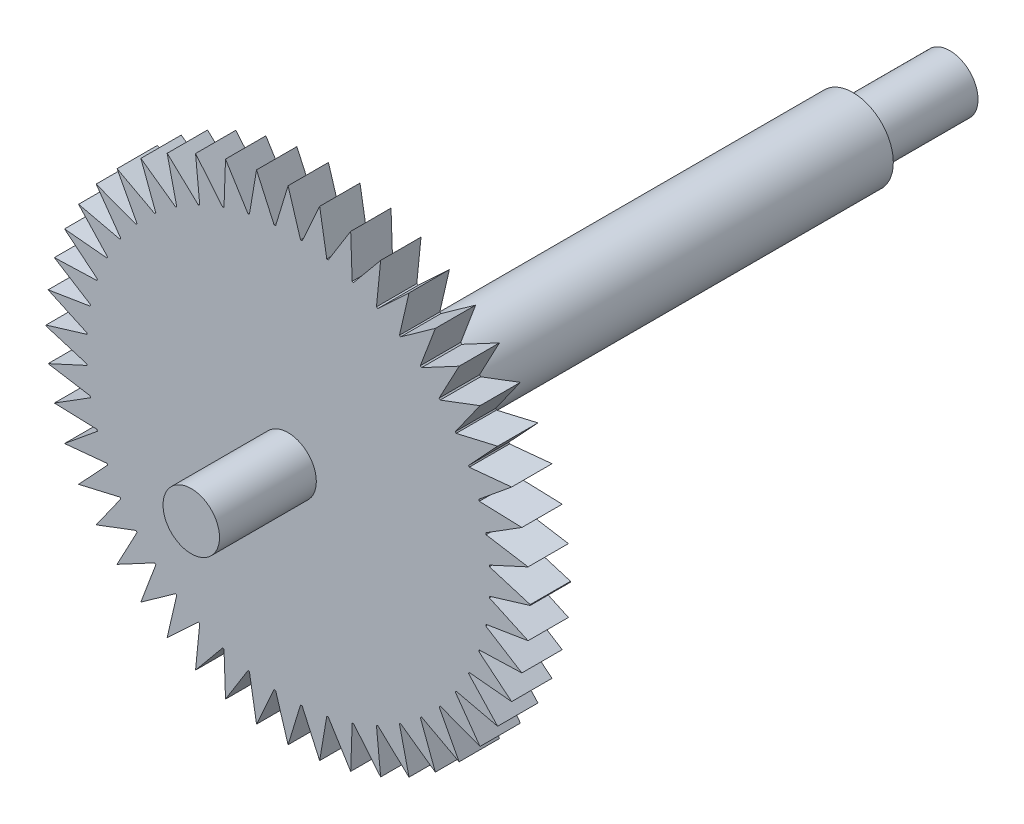
from build123d import *

# Parameters (mm, degrees)
ESQUISSE1_R             = 5
BOSS_EXTRU_1_DEPTH      = 70
ESQUISSE2_R             = 30
BOSS_EXTRU_2_DEPTH      = 5
ESQUISSE3_R             = 3.5
BOSS_EXTRU_3_DEPTH      = 12
ESQUISSE4_R             = 3.5
BOSS_EXTRU_4_DEPTH      = 12
ENL_V_MAT_EXTRU_1_DEPTH = 10


with BuildPart() as part:
    # Esquisse1 → Boss.-Extru.1 (new body)
    with BuildSketch(Plane.XY):
        Circle(ESQUISSE1_R)
    extrude(amount=BOSS_EXTRU_1_DEPTH)

    # Esquisse2 → Boss.-Extru.2 (add)
    with BuildSketch(Plane.XY.offset(70)):
        Circle(ESQUISSE2_R)
    extrude(amount=-BOSS_EXTRU_2_DEPTH)

    # Esquisse3 → Boss.-Extru.3 (add)
    with BuildSketch(Plane(origin=(0, 0, 0), x_dir=(-1, 0, 0), z_dir=(0, 0, -1))):
        Circle(ESQUISSE3_R)
    extrude(amount=BOSS_EXTRU_3_DEPTH)

    # Esquisse4 → Boss.-Extru.4 (add)
    with BuildSketch(Plane.XY.offset(70)):
        Circle(ESQUISSE4_R)
    extrude(amount=BOSS_EXTRU_4_DEPTH)

    # Esquisse5 → Enlèv. mat.-Extru.1 (cut)
    with BuildSketch(Plane.XY.offset(70)):
        with BuildLine():
            ThreePointArc((3.911624902, 29.743893333), (1.96, 29.935904864), (0, 30))
            Line((0, 30), (1.54, 24.952522919))
            ThreePointArc((1.54, 24.952522919), (1.639797772, 24.946163298), (1.739569306, 24.939404536))
            Line((1.739569306, 24.939404536), (3.911624902, 29.743893333))
        make_face()
        with BuildLine():
            Line((-1.54, 24.952522919), (0, 30))
            ThreePointArc((0, 30), (-1.96, 29.935904864), (-3.911624902, 29.743893333))
            Line((-3.911624902, 29.743893333), (-1.739569306, 24.939404536))
            ThreePointArc((-1.739569306, 24.939404536), (-1.639797772, 24.946163298), (-1.54, 24.952522919))
        make_face()
        with BuildLine():
            ThreePointArc((7.75646359, 28.979946042), (5.846535396, 29.424785876), (3.911624902, 29.743893333))
            Line((3.911624902, 29.743893333), (4.793067146, 24.536228466))
            ThreePointArc((4.793067146, 24.536228466), (4.878466786, 24.519391547), (4.963807286, 24.50225739))
            Line((4.963807286, 24.50225739), (7.75646359, 28.979946042))
        make_face()
        with BuildLine():
            Line((-4.793067146, 24.536228466), (-3.911624902, 29.743893333))
            ThreePointArc((-3.911624902, 29.743893333), (-5.846535396, 29.424785876), (-7.75646359, 28.979946042))
            Line((-7.75646359, 28.979946042), (-4.963807286, 24.50225739))
            ThreePointArc((-4.963807286, 24.50225739), (-4.878466786, 24.519391547), (-4.793067146, 24.536228466))
        make_face()
        with BuildLine():
            ThreePointArc((11.468870142, 27.721201591), (9.633248345, 28.411274634), (7.75646359, 28.979946042))
            Line((7.75646359, 28.979946042), (7.939081747, 23.705927128))
            ThreePointArc((7.939081747, 23.705927128), (8.021571427, 23.678141647), (8.103963866, 23.650069126))
            Line((8.103963866, 23.650069126), (11.468870142, 27.721201591))
        make_face()
        with BuildLine():
            Line((-7.939081747, 23.705927128), (-7.75646359, 28.979946042))
            ThreePointArc((-7.75646359, 28.979946042), (-9.633248345, 28.411274634), (-11.468870142, 27.721201591))
            Line((-11.468870142, 27.721201591), (-8.103963866, 23.650069126))
            ThreePointArc((-8.103963866, 23.650069126), (-8.021571427, 23.678141647), (-7.939081747, 23.705927128))
        make_face()
        with BuildLine():
            ThreePointArc((14.985459754, 25.989151505), (13.255485353, 26.912675602), (11.468870142, 27.721201591))
            Line((11.468870142, 27.721201591), (10.950617091, 22.474073626))
            ThreePointArc((10.950617091, 22.474073626), (11.04042578, 22.430091364), (11.130057821, 22.38575022))
            Line((11.130057821, 22.38575022), (14.985459754, 25.989151505))
        make_face()
        with BuildLine():
            Line((-10.950617091, 22.474073626), (-11.468870142, 27.721201591))
            ThreePointArc((-11.468870142, 27.721201591), (-13.255485353, 26.912675602), (-14.985459754, 25.989151505))
            Line((-14.985459754, 25.989151505), (-11.130057821, 22.38575022))
            ThreePointArc((-11.130057821, 22.38575022), (-11.04042578, 22.430091364), (-10.950617091, 22.474073626))
        make_face()
        with BuildLine():
            ThreePointArc((18.246190956, 23.813368422), (16.65140115, 24.954575527), (14.985459754, 25.989151505))
            Line((14.985459754, 25.989151505), (13.798277376, 20.847243018))
            ThreePointArc((13.798277376, 20.847243018), (13.870778356, 20.799074686), (13.943111187, 20.750654217))
            Line((13.943111187, 20.750654217), (18.246190956, 23.813368422))
        make_face()
        with BuildLine():
            Line((-13.798277376, 20.847243018), (-14.985459754, 25.989151505))
            ThreePointArc((-14.985459754, 25.989151505), (-16.65140115, 24.954575527), (-18.246190956, 23.813368422))
            Line((-18.246190956, 23.813368422), (-13.943111187, 20.750654217))
            ThreePointArc((-13.943111187, 20.750654217), (-13.870778356, 20.799074686), (-13.798277376, 20.847243018))
        make_face()
        with BuildLine():
            ThreePointArc((21.195390749, 21.231001177), (19.763014623, 22.570406576), (18.246190956, 23.813368422))
            Line((18.246190956, 23.813368422), (16.388920873, 18.878645942))
            ThreePointArc((16.388920873, 18.878645942), (16.464304345, 18.812939229), (16.539424387, 18.746931507))
            Line((16.539424387, 18.746931507), (21.195390749, 21.231001177))
        make_face()
        with BuildLine():
            Line((-16.388920873, 18.878645942), (-18.246190956, 23.813368422))
            ThreePointArc((-18.246190956, 23.813368422), (-19.763014623, 22.570406576), (-21.195390749, 21.231001177))
            Line((-21.195390749, 21.231001177), (-16.539424387, 18.746931507))
            ThreePointArc((-16.539424387, 18.746931507), (-16.464304345, 18.812939229), (-16.388920873, 18.878645942))
        make_face()
        with BuildLine():
            ThreePointArc((23.78270515, 18.286140537), (22.537198777, 19.800875518), (21.195390749, 21.231001177))
            Line((21.195390749, 21.231001177), (18.719140508, 16.57087139))
            ThreePointArc((18.719140508, 16.57087139), (18.78527424, 16.495862261), (18.851107406, 16.420589196))
            Line((18.851107406, 16.420589196), (23.78270515, 18.286140537))
        make_face()
        with BuildLine():
            Line((-18.719140508, 16.57087139), (-21.195390749, 21.231001177))
            ThreePointArc((-21.195390749, 21.231001177), (-22.537198777, 19.800875518), (-23.78270515, 18.286140537))
            Line((-23.78270515, 18.286140537), (-18.851107406, 16.420589196))
            ThreePointArc((-18.851107406, 16.420589196), (-18.78527424, 16.495862261), (-18.719140508, 16.57087139))
        make_face()
        with BuildLine():
            ThreePointArc((25.963958928, 15.029066397), (24.926587807, 16.693268712), (23.78270515, 18.286140537))
            Line((23.78270515, 18.286140537), (20.727218802, 13.97792548))
            ThreePointArc((20.727218802, 13.97792548), (20.775760628, 13.905674034), (20.824050599, 13.833254016))
            Line((20.824050599, 13.833254016), (25.963958928, 15.029066397))
        make_face()
        with BuildLine():
            Line((-20.727218802, 13.97792548), (-23.78270515, 18.286140537))
            ThreePointArc((-23.78270515, 18.286140537), (-24.926587807, 16.693268712), (-25.963958928, 15.029066397))
            Line((-25.963958928, 15.029066397), (-20.824050599, 13.833254016))
            ThreePointArc((-20.824050599, 13.833254016), (-20.775760628, 13.905674034), (-20.727218802, 13.97792548))
        make_face()
        with BuildLine():
            ThreePointArc((27.701909842, 11.515389317), (26.890385817, 13.300644745), (25.963958928, 15.029066397))
            Line((25.963958928, 15.029066397), (22.367034749, 11.167620899))
            ThreePointArc((22.367034749, 11.167620899), (22.405781894, 11.089677079), (22.444257425, 11.011598824))
            Line((22.444257425, 11.011598824), (27.701909842, 11.515389317))
        make_face()
        with BuildLine():
            Line((-22.367034749, 11.167620899), (-25.963958928, 15.029066397))
            ThreePointArc((-25.963958928, 15.029066397), (-26.890385817, 13.300644745), (-27.701909842, 11.515389317))
            Line((-27.701909842, 11.515389317), (-22.444257425, 11.011598824))
            ThreePointArc((-22.444257425, 11.011598824), (-22.405781894, 11.089677079), (-22.367034749, 11.167620899))
        make_face()
        with BuildLine():
            ThreePointArc((28.966884502, 7.805101039), (28.395063354, 9.680928526), (27.701909842, 11.515389317))
            Line((27.701909842, 11.515389317), (23.627977885, 8.168149181))
            ThreePointArc((23.627977885, 8.168149181), (23.660461458, 8.073571924), (23.692566461, 7.97886549))
            Line((23.692566461, 7.97886549), (28.966884502, 7.805101039))
        make_face()
        with BuildLine():
            Line((-23.627977885, 8.168149181), (-27.701909842, 11.515389317))
            ThreePointArc((-27.701909842, 11.515389317), (-28.395063354, 9.680928526), (-28.966884502, 7.805101039))
            Line((-28.966884502, 7.805101039), (-23.692566461, 7.97886549))
            ThreePointArc((-23.692566461, 7.97886549), (-23.660461458, 8.073571924), (-23.627977885, 8.168149181))
        make_face()
        with BuildLine():
            ThreePointArc((29.737285014, 3.9615502), (29.41492989, 5.895922284), (28.966884502, 7.805101039))
            Line((28.966884502, 7.805101039), (24.493890167, 5.004932014))
            ThreePointArc((24.493890167, 5.004932014), (24.513713944, 4.906916414), (24.533145499, 4.808822302))
            Line((24.533145499, 4.808822302), (29.737285014, 3.9615502))
        make_face()
        with BuildLine():
            Line((-24.493890167, 5.004932014), (-28.966884502, 7.805101039))
            ThreePointArc((-28.966884502, 7.805101039), (-29.41492989, 5.895922284), (-29.737285014, 3.9615502))
            Line((-29.737285014, 3.9615502), (-24.533145499, 4.808822302))
            ThreePointArc((-24.533145499, 4.808822302), (-24.513713944, 4.906916414), (-24.493890167, 5.004932014))
        make_face()
        with BuildLine():
            ThreePointArc((29.99995773, 0.050360733), (29.932572449, 2.010250376), (29.737285014, 3.9615502))
            Line((29.737285014, 3.9615502), (24.938282315, 1.755583995))
            ThreePointArc((24.938282315, 1.755583995), (24.944243639, 1.668744817), (24.949902576, 1.581885408))
            Line((24.949902576, 1.581885408), (29.99995773, 0.050360733))
        make_face()
        with BuildLine():
            Line((-24.938282315, 1.755583995), (-29.737285014, 3.9615502))
            ThreePointArc((-29.737285014, 3.9615502), (-29.932572449, 2.010250376), (-29.99995773, 0.050360733))
            Line((-29.99995773, 0.050360733), (-24.949902576, 1.581885408))
            ThreePointArc((-24.949902576, 1.581885408), (-24.944243639, 1.668744817), (-24.938282315, 1.755583995))
        make_face()
        with BuildLine():
            Line((-24.949902576, -1.581885408), (-29.99995773, -0.050360733))
            ThreePointArc((-29.99995773, -0.050360733), (-29.932572449, -2.010250376), (-29.737285014, -3.9615502))
            Line((-29.737285014, -3.9615502), (-24.938282315, -1.755583995))
            ThreePointArc((-24.938282315, -1.755583995), (-24.944243639, -1.668744817), (-24.949902576, -1.581885408))
        make_face()
        with BuildLine():
            ThreePointArc((29.737285014, -3.9615502), (29.932572449, -2.010250376), (29.99995773, -0.050360733))
            Line((29.99995773, -0.050360733), (24.949902576, -1.581885408))
            ThreePointArc((24.949902576, -1.581885408), (24.944243639, -1.668744817), (24.938282315, -1.755583995))
            Line((24.938282315, -1.755583995), (29.737285014, -3.9615502))
        make_face()
        with BuildLine():
            Line((-24.533145499, -4.808822302), (-29.737285014, -3.9615502))
            ThreePointArc((-29.737285014, -3.9615502), (-29.41492989, -5.895922284), (-28.966884502, -7.805101039))
            Line((-28.966884502, -7.805101039), (-24.493890167, -5.004932014))
            ThreePointArc((-24.493890167, -5.004932014), (-24.513713944, -4.906916414), (-24.533145499, -4.808822302))
        make_face()
        with BuildLine():
            ThreePointArc((28.966884502, -7.805101039), (29.41492989, -5.895922284), (29.737285014, -3.9615502))
            Line((29.737285014, -3.9615502), (24.533145499, -4.808822302))
            ThreePointArc((24.533145499, -4.808822302), (24.513713944, -4.906916414), (24.493890167, -5.004932014))
            Line((24.493890167, -5.004932014), (28.966884502, -7.805101039))
        make_face()
        with BuildLine():
            Line((-23.692566461, -7.97886549), (-28.966884502, -7.805101039))
            ThreePointArc((-28.966884502, -7.805101039), (-28.395063354, -9.680928526), (-27.701909842, -11.515389317))
            Line((-27.701909842, -11.515389317), (-23.627977885, -8.168149181))
            ThreePointArc((-23.627977885, -8.168149181), (-23.660461458, -8.073571924), (-23.692566461, -7.97886549))
        make_face()
        with BuildLine():
            ThreePointArc((27.701909842, -11.515389317), (28.395063354, -9.680928526), (28.966884502, -7.805101039))
            Line((28.966884502, -7.805101039), (23.692566461, -7.97886549))
            ThreePointArc((23.692566461, -7.97886549), (23.660461458, -8.073571924), (23.627977885, -8.168149181))
            Line((23.627977885, -8.168149181), (27.701909842, -11.515389317))
        make_face()
        with BuildLine():
            Line((-22.444257425, -11.011598824), (-27.701909842, -11.515389317))
            ThreePointArc((-27.701909842, -11.515389317), (-26.890385817, -13.300644745), (-25.963958928, -15.029066397))
            Line((-25.963958928, -15.029066397), (-22.367034749, -11.167620899))
            ThreePointArc((-22.367034749, -11.167620899), (-22.405781894, -11.089677079), (-22.444257425, -11.011598824))
        make_face()
        with BuildLine():
            ThreePointArc((25.963958928, -15.029066397), (26.890385817, -13.300644745), (27.701909842, -11.515389317))
            Line((27.701909842, -11.515389317), (22.444257425, -11.011598824))
            ThreePointArc((22.444257425, -11.011598824), (22.405781894, -11.089677079), (22.367034749, -11.167620899))
            Line((22.367034749, -11.167620899), (25.963958928, -15.029066397))
        make_face()
        with BuildLine():
            Line((-20.824050599, -13.833254016), (-25.963958928, -15.029066397))
            ThreePointArc((-25.963958928, -15.029066397), (-24.926587807, -16.693268712), (-23.78270515, -18.286140537))
            Line((-23.78270515, -18.286140537), (-20.727218802, -13.97792548))
            ThreePointArc((-20.727218802, -13.97792548), (-20.775760628, -13.905674034), (-20.824050599, -13.833254016))
        make_face()
        with BuildLine():
            ThreePointArc((23.78270515, -18.286140537), (24.926587807, -16.693268712), (25.963958928, -15.029066397))
            Line((25.963958928, -15.029066397), (20.824050599, -13.833254016))
            ThreePointArc((20.824050599, -13.833254016), (20.775760628, -13.905674034), (20.727218802, -13.97792548))
            Line((20.727218802, -13.97792548), (23.78270515, -18.286140537))
        make_face()
        with BuildLine():
            Line((-18.851107406, -16.420589196), (-23.78270515, -18.286140537))
            ThreePointArc((-23.78270515, -18.286140537), (-22.537198777, -19.800875518), (-21.195390749, -21.231001177))
            Line((-21.195390749, -21.231001177), (-18.719140508, -16.57087139))
            ThreePointArc((-18.719140508, -16.57087139), (-18.78527424, -16.495862261), (-18.851107406, -16.420589196))
        make_face()
        with BuildLine():
            ThreePointArc((21.195390749, -21.231001177), (22.537198777, -19.800875518), (23.78270515, -18.286140537))
            Line((23.78270515, -18.286140537), (18.851107406, -16.420589196))
            ThreePointArc((18.851107406, -16.420589196), (18.78527424, -16.495862261), (18.719140508, -16.57087139))
            Line((18.719140508, -16.57087139), (21.195390749, -21.231001177))
        make_face()
        with BuildLine():
            Line((-16.539424387, -18.746931507), (-21.195390749, -21.231001177))
            ThreePointArc((-21.195390749, -21.231001177), (-19.763014623, -22.570406576), (-18.246190956, -23.813368422))
            Line((-18.246190956, -23.813368422), (-16.388920873, -18.878645942))
            ThreePointArc((-16.388920873, -18.878645942), (-16.464304345, -18.812939229), (-16.539424387, -18.746931507))
        make_face()
        with BuildLine():
            ThreePointArc((18.246190956, -23.813368422), (19.763014623, -22.570406576), (21.195390749, -21.231001177))
            Line((21.195390749, -21.231001177), (16.539424387, -18.746931507))
            ThreePointArc((16.539424387, -18.746931507), (16.464304345, -18.812939229), (16.388920873, -18.878645942))
            Line((16.388920873, -18.878645942), (18.246190956, -23.813368422))
        make_face()
        with BuildLine():
            Line((-13.943111187, -20.750654217), (-18.246190956, -23.813368422))
            ThreePointArc((-18.246190956, -23.813368422), (-16.65140115, -24.954575527), (-14.985459754, -25.989151505))
            Line((-14.985459754, -25.989151505), (-13.798277376, -20.847243018))
            ThreePointArc((-13.798277376, -20.847243018), (-13.870778356, -20.799074686), (-13.943111187, -20.750654217))
        make_face()
        with BuildLine():
            ThreePointArc((14.985459754, -25.989151505), (16.65140115, -24.954575527), (18.246190956, -23.813368422))
            Line((18.246190956, -23.813368422), (13.943111187, -20.750654217))
            ThreePointArc((13.943111187, -20.750654217), (13.870778356, -20.799074686), (13.798277376, -20.847243018))
            Line((13.798277376, -20.847243018), (14.985459754, -25.989151505))
        make_face()
        with BuildLine():
            Line((-11.130057821, -22.38575022), (-14.985459754, -25.989151505))
            ThreePointArc((-14.985459754, -25.989151505), (-13.255485353, -26.912675602), (-11.468870142, -27.721201591))
            Line((-11.468870142, -27.721201591), (-10.950617091, -22.474073626))
            ThreePointArc((-10.950617091, -22.474073626), (-11.04042578, -22.430091364), (-11.130057821, -22.38575022))
        make_face()
        with BuildLine():
            ThreePointArc((11.468870142, -27.721201591), (13.255485353, -26.912675602), (14.985459754, -25.989151505))
            Line((14.985459754, -25.989151505), (11.130057821, -22.38575022))
            ThreePointArc((11.130057821, -22.38575022), (11.04042578, -22.430091364), (10.950617091, -22.474073626))
            Line((10.950617091, -22.474073626), (11.468870142, -27.721201591))
        make_face()
        with BuildLine():
            Line((-8.103963866, -23.650069126), (-11.468870142, -27.721201591))
            ThreePointArc((-11.468870142, -27.721201591), (-9.633248345, -28.411274634), (-7.75646359, -28.979946042))
            Line((-7.75646359, -28.979946042), (-7.939081747, -23.705927128))
            ThreePointArc((-7.939081747, -23.705927128), (-8.021571427, -23.678141647), (-8.103963866, -23.650069126))
        make_face()
        with BuildLine():
            ThreePointArc((7.75646359, -28.979946042), (9.633248345, -28.411274634), (11.468870142, -27.721201591))
            Line((11.468870142, -27.721201591), (8.103963866, -23.650069126))
            ThreePointArc((8.103963866, -23.650069126), (8.021571427, -23.678141647), (7.939081747, -23.705927128))
            Line((7.939081747, -23.705927128), (7.75646359, -28.979946042))
        make_face()
        with BuildLine():
            Line((-4.963807286, -24.50225739), (-7.75646359, -28.979946042))
            ThreePointArc((-7.75646359, -28.979946042), (-5.846535396, -29.424785876), (-3.911624902, -29.743893333))
            Line((-3.911624902, -29.743893333), (-4.793067146, -24.536228466))
            ThreePointArc((-4.793067146, -24.536228466), (-4.878466786, -24.519391547), (-4.963807286, -24.50225739))
        make_face()
        with BuildLine():
            ThreePointArc((3.911624902, -29.743893333), (5.846535396, -29.424785876), (7.75646359, -28.979946042))
            Line((7.75646359, -28.979946042), (4.963807286, -24.50225739))
            ThreePointArc((4.963807286, -24.50225739), (4.878466786, -24.519391547), (4.793067146, -24.536228466))
            Line((4.793067146, -24.536228466), (3.911624902, -29.743893333))
        make_face()
        with BuildLine():
            Line((-1.739569306, -24.939404536), (-3.911624902, -29.743893333))
            ThreePointArc((-3.911624902, -29.743893333), (-1.96, -29.935904864), (0, -30))
            Line((0, -30), (-1.54, -24.952522919))
            ThreePointArc((-1.54, -24.952522919), (-1.639797772, -24.946163298), (-1.739569306, -24.939404536))
        make_face()
        with BuildLine():
            ThreePointArc((0, -30), (1.96, -29.935904864), (3.911624902, -29.743893333))
            Line((3.911624902, -29.743893333), (1.739569306, -24.939404536))
            ThreePointArc((1.739569306, -24.939404536), (1.639797772, -24.946163298), (1.54, -24.952522919))
            Line((1.54, -24.952522919), (0, -30))
        make_face()
    extrude(amount=-ENL_V_MAT_EXTRU_1_DEPTH, mode=Mode.SUBTRACT)


solid = part.part
